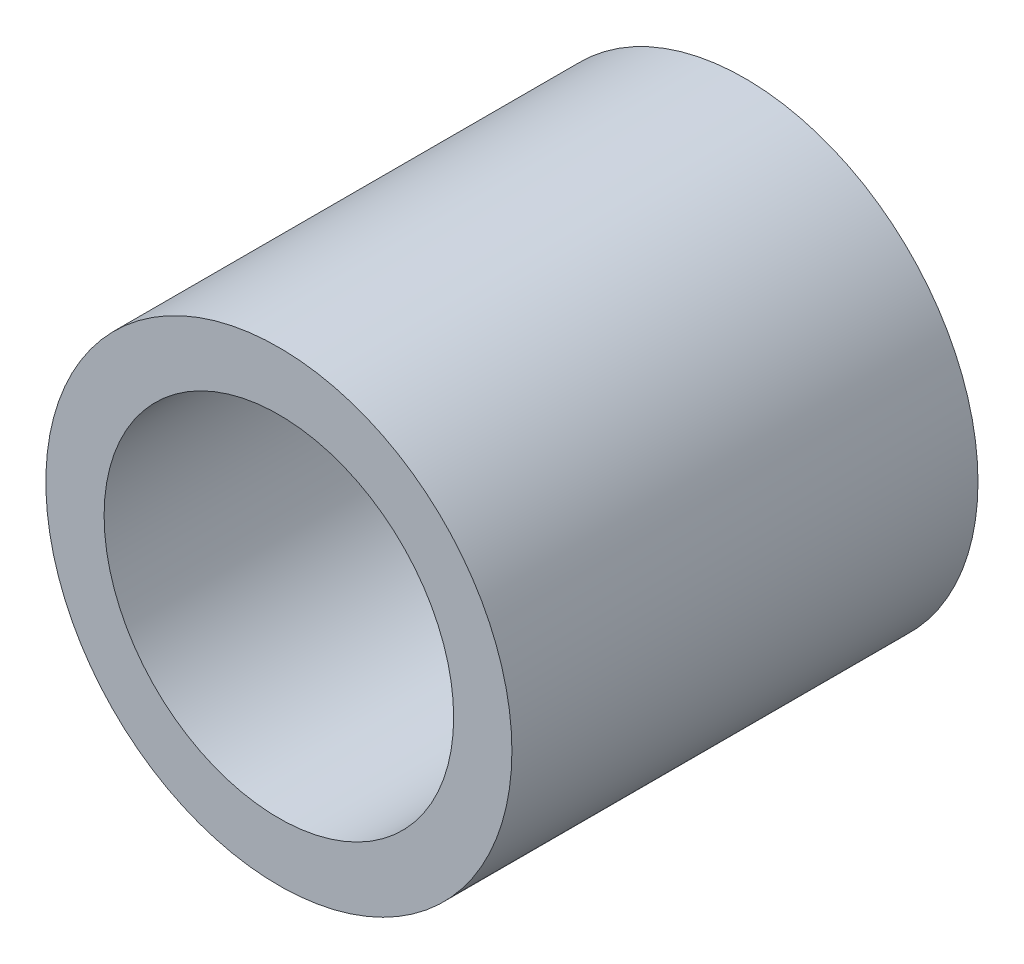
from build123d import *

# Parameters (mm, degrees)
SKETCH1_R           = 2
SKETCH1_R_2         = 1.5
BOSS_EXTRUDE1_DEPTH = 4


with BuildPart() as part:
    # Sketch1 → Boss-Extrude1 (new body)
    with BuildSketch(Plane.XY):
        Circle(SKETCH1_R)
        Circle(SKETCH1_R_2, mode=Mode.SUBTRACT)
    extrude(amount=BOSS_EXTRUDE1_DEPTH)


solid = part.part
